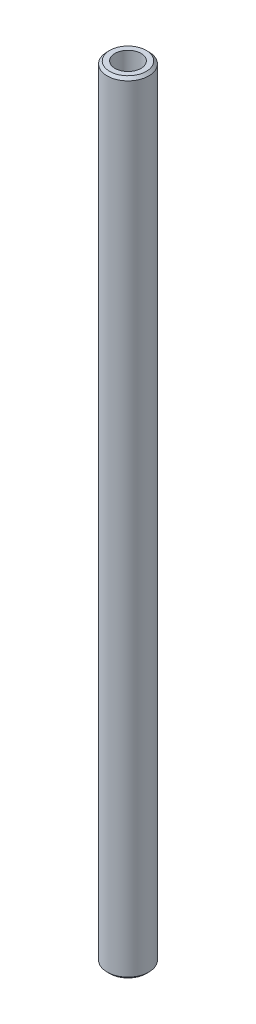
from build123d import *

# Parameters (mm, degrees)
ESQUISSE1_R      = 4
EXTRUSION1_DEPTH = 150
CHANFREIN1_SIZE  = 0.5
ESQUISSE2_R      = 2.5
EXTRUSION2_DEPTH = 15
ESQUISSE3_R      = 2.5
EXTRUSION3_DEPTH = 15


with BuildPart() as part:
    # Esquisse1 → Extrusion1 (new body)
    with BuildSketch(Plane(origin=(0, 0, 0), x_dir=(1, 0, 0), z_dir=(0, 1, 0))):
        Circle(ESQUISSE1_R)
    extrude(amount=EXTRUSION1_DEPTH)

    # Chanfrein1
    chanfrein1_edges = [part.edges().sort_by_distance(p)[0] for p in [
        (-4, 0, 0),
        (-4, 150, 0),
    ]]
    chamfer(chanfrein1_edges, length=CHANFREIN1_SIZE)

    # Esquisse2 → Extrusion2 (cut)
    with BuildSketch(Plane.XZ):
        Circle(ESQUISSE2_R)
    extrude(amount=-EXTRUSION2_DEPTH, mode=Mode.SUBTRACT)

    # Esquisse3 → Extrusion3 (cut)
    with BuildSketch(Plane(origin=(0, 150, 0), x_dir=(1, 0, 0), z_dir=(0, 1, 0))):
        Circle(ESQUISSE3_R)
    extrude(amount=-EXTRUSION3_DEPTH, mode=Mode.SUBTRACT)


solid = part.part
